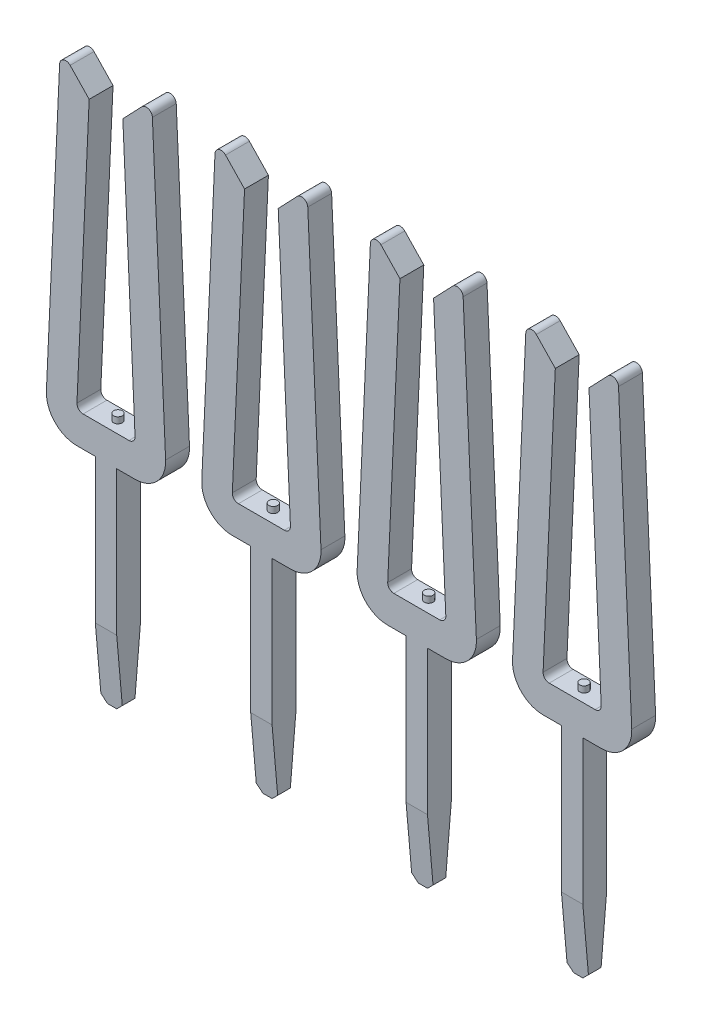
from build123d import *

# Parameters (mm, degrees)
EXTRUDE_683_DEPTH        = 0.195
CHAMFER_1_SIZE           = 0.1
CHAMFER_1_SIZE2          = 1.14300523
CHAMFER_2_SIZE           = 0.1
CHAMFER_2_SIZE2          = 1.14300523
ESBO_O1_R                = 0.071480511
RESSALTO_EXTRUS_O1_DEPTH = 0.1
PATTERN_LINEAR_1_COUNT   = 4
PATTERN_LINEAR_1_PITCH   = 2.54


with BuildPart() as part:
    # Sketch 210 → Extrude 683 (new, symmetric)
    with BuildSketch(Plane.XY):
        with BuildLine():
            Line((-0.275094226, 4.504536299), (-0.585991311, 4.829871514))
            ThreePointArc((-0.585991311, 4.829871514), (-0.693381247, 4.85442336), (-0.758184185, 4.765339295))
            Line((-0.758184185, 4.765339295), (-0.974480797, 0.022780107))
            ThreePointArc((-0.974480797, 0.022780107), (-0.836517671, -0.34540552), (-0.475, -0.5))
            Line((-0.475, -0.5), (-0.175, -0.5))
            Line((-0.175, -0.5), (-0.175, -3.9))
            Line((-0.175, -3.9), (-0.075, -4))
            Line((-0.075, -4), (0.075, -4))
            Line((0.075, -4), (0.175, -3.9))
            Line((0.175, -3.9), (0.175, -0.5))
            Line((0.175, -0.5), (0.475, -0.5))
            ThreePointArc((0.475, -0.5), (0.836517671, -0.34540552), (0.974480797, 0.022780107))
            Line((0.974480797, 0.022780107), (0.758184185, 4.765339295))
            ThreePointArc((0.758184185, 4.765339295), (0.693381247, 4.85442336), (0.585991311, 4.829871514))
            Line((0.585991311, 4.829871514), (0.275094226, 4.504536299))
            Line((0.275094226, 4.504536299), (0.474897057, 0.104536299))
            ThreePointArc((0.474897057, 0.104536299), (0.447296715, 0.030911759), (0.375, 0))
            Line((0.375, 0), (-0.375, 0))
            ThreePointArc((-0.375, 0), (-0.447296715, 0.030911759), (-0.474897057, 0.104536299))
            Line((-0.474897057, 0.104536299), (-0.275094226, 4.504536299))
        make_face()
    extrude(amount=EXTRUDE_683_DEPTH, both=True)

    # Фаска1
    chamfer_1_edges = [part.edges().sort_by_distance(p)[0] for p in [
        (0, -4, 0.195),
    ]]
    chamfer_1_side = [part.faces().sort_by_distance(p)[0] for p in [
        (0, -4, 0),
    ]]
    chamfer(chamfer_1_edges, length=CHAMFER_1_SIZE, length2=CHAMFER_1_SIZE2, reference=chamfer_1_side[0])

    # Фаска2
    chamfer_2_edges = [part.edges().sort_by_distance(p)[0] for p in [
        (0, -4, -0.195),
    ]]
    chamfer_2_side = [part.faces().sort_by_distance(p)[0] for p in [
        (0, -4, -0.05),
    ]]
    chamfer(chamfer_2_edges, length=CHAMFER_2_SIZE, length2=CHAMFER_2_SIZE2, reference=chamfer_2_side[0])

    # Esboço1 → Ressalto-extrusão1 (add)
    with BuildSketch(Plane(origin=(0, 0, 0), x_dir=(1, 0, 0), z_dir=(0, 1, 0))):
        Circle(ESBO_O1_R)
    extrude(amount=RESSALTO_EXTRUS_O1_DEPTH)


with BuildPart() as pattern_linear_1_1:
    # Линейный массив1: pattern copy
    add(part.part.moved(Location(Vector(-1, 0, 0) * (1 * PATTERN_LINEAR_1_PITCH))))


with BuildPart() as pattern_linear_1_2:
    # Линейный массив1: pattern copy
    add(part.part.moved(Location(Vector(-1, 0, 0) * (2 * PATTERN_LINEAR_1_PITCH))))


with BuildPart() as pattern_linear_1_3:
    # Линейный массив1: pattern copy
    add(part.part.moved(Location(Vector(-1, 0, 0) * (3 * PATTERN_LINEAR_1_PITCH))))


solid = Compound([part.part, pattern_linear_1_1.part, pattern_linear_1_2.part, pattern_linear_1_3.part])
